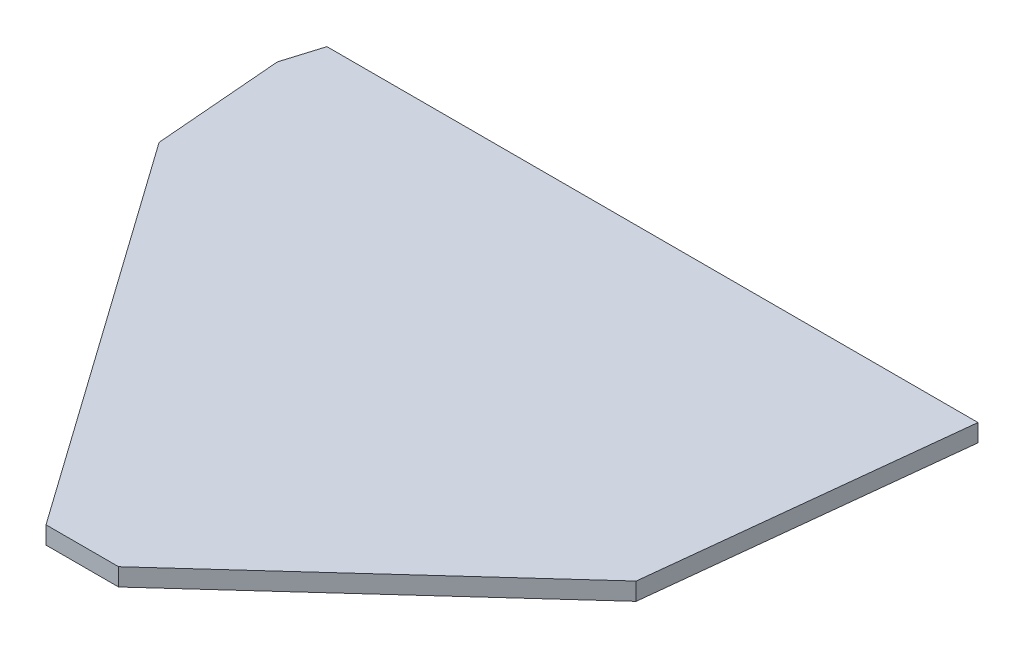
from build123d import *

# Parameters (mm, degrees)
BOSS_EXTRU_1_DEPTH = 2


with BuildPart() as part:
    # Esquisse1 → Boss.-Extru.1 (new body)
    with BuildSketch(Plane(origin=(0, 0, 0), x_dir=(1, 0, 0), z_dir=(0, 1, 0))):
        Polygon((39.081242525, 28.004698974), (42.906292993, 63.04123288), (-31.105576244, 63.04123288), (-32.421620527, 58.722734784), (-31.221557336, 44.078217395), (0, 0), (8.247303282, 0), align=None)
    extrude(amount=BOSS_EXTRU_1_DEPTH)


solid = part.part
